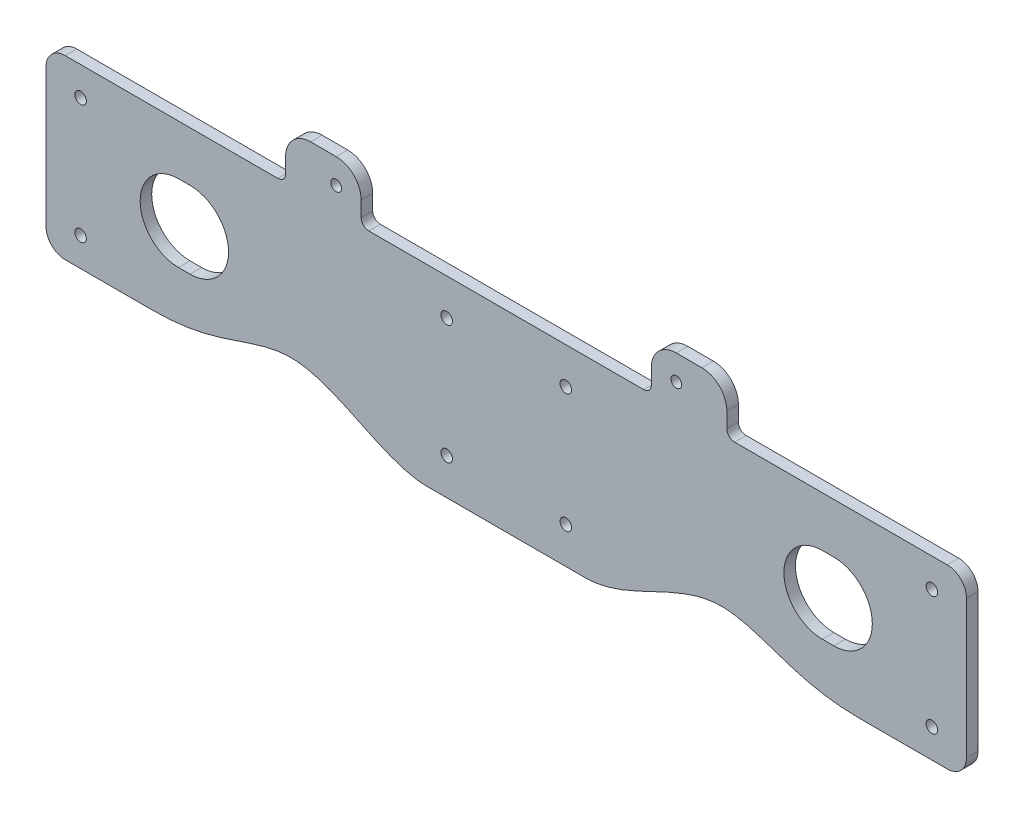
from build123d import *

# Parameters (mm, degrees)
SKETCH1_W           = 119.75
SKETCH1_H           = 50
BOSS_EXTRUDE1_DEPTH = 3
SKETCH2_R           = 1.5
CUT_EXTRUDE1_DEPTH  = 3
SKETCH3_R           = 1.4
BOSS_EXTRUDE2_DEPTH = 3
FILLET1_R           = 2
CUT_EXTRUDE2_DEPTH  = 10
FILLET2_R           = 5
CUT_EXTRUDE3_DEPTH  = 10


with BuildPart() as part:
    # Sketch1 → Boss-Extrude1 (new body)
    with BuildSketch(Plane.XY):
        with Locations((59.875, 25)):
            Rectangle(SKETCH1_W, SKETCH1_H)
    extrude(amount=BOSS_EXTRUDE1_DEPTH)

    # Sketch2 → Cut-Extrude1 (cut)
    with BuildSketch(Plane(origin=(0, 0, 0), x_dir=(-1, 0, 0), z_dir=(0, 0, -1))):
        with Locations((-104.25, 40.5)):
            Circle(SKETCH2_R)
        with Locations((-104.25, 9.5)):
            Circle(SKETCH2_R)
        with Locations((-9, 42.5)):
            Circle(SKETCH2_R)
        with Locations((-9, 11.5)):
            Circle(SKETCH2_R)
    extrude(amount=-CUT_EXTRUDE1_DEPTH, mode=Mode.SUBTRACT)

    # Mirror1: part across plane


with BuildPart() as part_1:
    add(part.part)
    add(part.part.mirror(Plane(origin=(119.75, 0, 3), x_dir=(0, 0, 1), z_dir=(-1, 0, 0))))

    # Sketch3 → Boss-Extrude2 (add)
    with BuildSketch(Plane(origin=(0, 0, 0), x_dir=(-1, 0, 0), z_dir=(0, 0, -1))):
        with BuildLine():
            Line((-82, 50), (-82, 56))
            ThreePointArc((-82, 56), (-80.096194078, 60.596194078), (-75.5, 62.5))
            Line((-75.5, 62.5), (-68.843823796, 62.5))
            ThreePointArc((-68.843823796, 62.5), (-64.247629718, 60.596194078), (-62.343823796, 56))
            Line((-62.343823796, 56), (-62.343823796, 50))
            Line((-62.343823796, 50), (-82, 50))
        make_face()
        with Locations((-75.5, 56)):
            Circle(SKETCH3_R, mode=Mode.SUBTRACT)
    boss_extrude2 = extrude(amount=-BOSS_EXTRUDE2_DEPTH)

    # Mirror2: Boss-Extrude2 across plane
    add(boss_extrude2.mirror(Plane(origin=(119.75, 0, 0), x_dir=(0, 0, 1), z_dir=(1, 0, 0))))

    # Fillet1
    fillet1_edges = [part_1.edges().sort_by_distance(p)[0] for p in [
        (177.156176204, 50, 1.5),
        (157.5, 50, 1.5),
        (62.343823796, 50, 1.5),
        (82, 50, 1.5),
    ]]
    fillet(fillet1_edges, radius=FILLET1_R)

    # Sketch4 → Cut-Extrude2 (cut)
    with BuildSketch(Plane(origin=(0, 0, 0), x_dir=(-1, 0, 0), z_dir=(0, 0, -1))):
        with BuildLine():
            Line((-27.655095692, 4), (0, 4))
            Line((0, 4), (0, 0))
            Line((0, 0), (-99.256160352, 0))
            add(Edge.make_bspline(
                [(-99.256160352, 0), (-90.116604623, 0), (-79.005268065, 8.449150394), (-62.736804921, 12.15262313), (-50.625142782, 8.672513345), (-38.701859446, 4), (-27.655095692, 4)],
                knots=[0, 0, 0, 0, 0.434613944, 0.535270934, 0.727022104, 1, 1, 1, 1], degree=3))
        make_face()
    cut_extrude2 = extrude(amount=-CUT_EXTRUDE2_DEPTH, mode=Mode.SUBTRACT)

    # Mirror3: Cut-Extrude2 across plane
    add(cut_extrude2.mirror(Plane(origin=(119.75, 0, 0), x_dir=(0, 0, 1), z_dir=(1, 0, 0))), mode=Mode.SUBTRACT)

    # Fillet2
    fillet2_edges = [part_1.edges().sort_by_distance(p)[0] for p in [
        (239.5, 4, 1.5),
        (239.5, 50, 1.5),
        (0, 4, 1.5),
        (0, 50, 1.5),
    ]]
    fillet(fillet2_edges, radius=FILLET2_R)

    # Sketch5 → Cut-Extrude3 (cut)
    with BuildSketch(Plane(origin=(0, 0, 0), x_dir=(-1, 0, 0), z_dir=(0, 0, -1))):
        with BuildLine():
            Line((-34.5, 17), (-37.5, 17))
            ThreePointArc((-37.5, 17), (-47.5, 27), (-37.5, 37))
            Line((-37.5, 37), (-34.5, 37))
            ThreePointArc((-34.5, 37), (-24.5, 27), (-34.5, 17))
        make_face()
    cut_extrude3 = extrude(amount=-CUT_EXTRUDE3_DEPTH, mode=Mode.SUBTRACT)

    # Mirror4: Cut-Extrude3 across plane
    add(cut_extrude3.mirror(Plane(origin=(119.75, 0, 0), x_dir=(0, 0, 1), z_dir=(1, 0, 0))), mode=Mode.SUBTRACT)


solid = part_1.part
